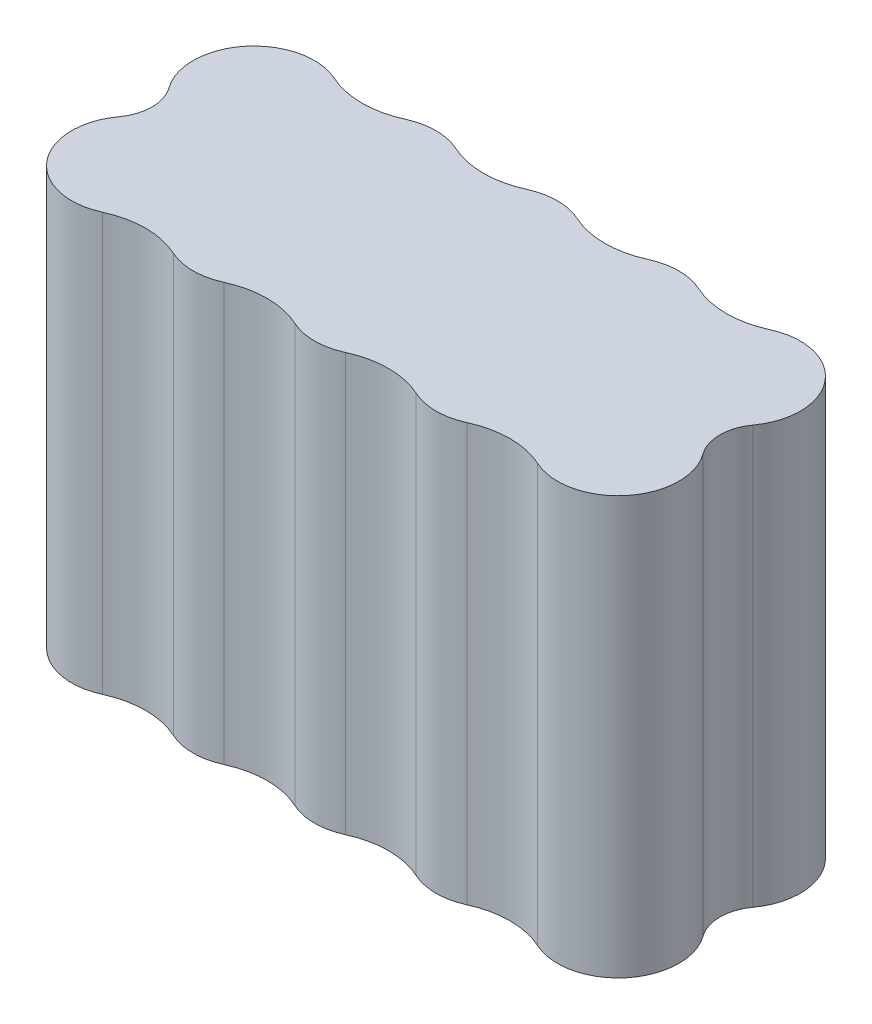
from build123d import *

# Parameters (mm, degrees)
BOSS_EXTRUDE1_DEPTH = 49
FILLET1_R           = 10
FILLET2_R           = 5


with BuildPart() as part:
    # Sketch1 → Boss-Extrude1 (new body)
    with BuildSketch(Plane(origin=(0, 0, 0), x_dir=(1, 0, 0), z_dir=(0, 1, 0))):
        with BuildLine():
            ThreePointArc((-74.859210096, 7.125), (-87.022345912, 12.163135816), (-81.984210096, 0))
            ThreePointArc((-81.984210096, 0), (-87.022345912, -12.163135816), (-74.859210096, -7.125))
            ThreePointArc((-74.859210096, -7.125), (-67.734210096, -14.25), (-60.609210096, -7.125))
            ThreePointArc((-60.609210096, -7.125), (-53.484210096, -14.25), (-46.359210096, -7.125))
            ThreePointArc((-46.359210096, -7.125), (-39.234210096, -14.25), (-32.109210096, -7.125))
            ThreePointArc((-32.109210096, -7.125), (-19.94607428, -12.163135816), (-24.984210096, 0))
            ThreePointArc((-24.984210096, 0), (-19.94607428, 12.163135816), (-32.109210096, 7.125))
            ThreePointArc((-32.109210096, 7.125), (-39.234210096, 14.25), (-46.359210096, 7.125))
            ThreePointArc((-46.359210096, 7.125), (-53.484210096, 14.25), (-60.609210096, 7.125))
            ThreePointArc((-60.609210096, 7.125), (-67.734210096, 14.25), (-74.859210096, 7.125))
        make_face()
    extrude(amount=BOSS_EXTRUDE1_DEPTH)

    # Fillet1
    fillet1_edges = [part.edges().sort_by_distance(p)[0] for p in [
        (-74.859210096, 24.5, -7.125),
        (-60.609210096, 24.5, -7.125),
        (-46.359210096, 24.5, -7.125),
        (-32.109210096, 24.5, -7.125),
        (-32.109210096, 24.5, 7.125),
        (-46.359210096, 24.5, 7.125),
        (-60.609210096, 24.5, 7.125),
        (-74.859210096, 24.5, 7.125),
    ]]
    fillet(fillet1_edges, radius=FILLET1_R)

    # Fillet2
    fillet2_edges = [part.edges().sort_by_distance(p)[0] for p in [
        (-81.984210096, 24.5, 0),
        (-24.984210096, 24.5, 0),
    ]]
    fillet(fillet2_edges, radius=FILLET2_R)


solid = part.part
